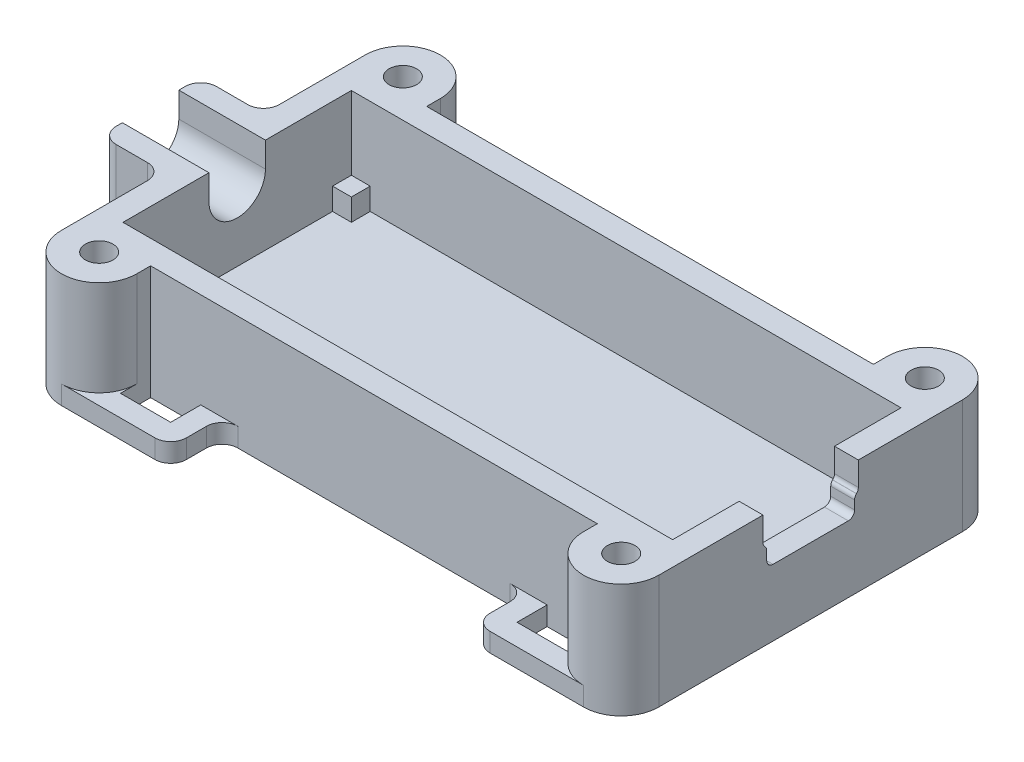
from build123d import *

# Parameters (mm, degrees)
SKETCH1_W           = 43.8
SKETCH1_H           = 18.2
SKETCH1_R           = 1.1
BOSS_EXTRUDE1_DEPTH = 7.6
SKETCH3_R           = 1.1
BOSS_EXTRUDE2_DEPTH = 1.5
CUT_EXTRUDE1_REACH  = 54.6
SKETCH5_W           = 1.5
SKETCH5_H           = 1.5
BOSS_EXTRUDE3_DEPTH = 1.75
CUT_EXTRUDE2_REACH  = 54.6
BOSS_EXTRUDE4_DEPTH = 1.5
FILLET1_R           = 1.25
FILLET2_R           = 0.5


with BuildPart() as part:
    # Sketch1 → Boss-Extrude1 (new body)
    with BuildSketch(Plane(origin=(0, 0, 0), x_dir=(1, 0, 0), z_dir=(0, 1, 0))):
        with BuildLine():
            ThreePointArc((-23.8, -12.1), (-20.8, -15.1), (-17.8, -12.1))
            Line((-17.8, -12.1), (-17.8, -11))
            Line((-17.8, -11), (17.8, -11))
            Line((17.8, -11), (17.8, -12.1))
            ThreePointArc((17.8, -12.1), (20.8, -15.1), (23.8, -12.1))
            Line((23.8, -12.1), (23.8, 12.1))
            ThreePointArc((23.8, 12.1), (20.8, 15.1), (17.8, 12.1))
            Line((17.8, 12.1), (17.8, 11))
            Line((17.8, 11), (-17.8, 11))
            Line((-17.8, 11), (-17.8, 12.1))
            ThreePointArc((-17.8, 12.1), (-20.8, 15.1), (-23.8, 12.1))
            Line((-23.8, 12.1), (-23.8, 4))
            Line((-23.8, 4), (-28.8, 4))
            Line((-28.8, 4), (-28.8, -4))
            Line((-28.8, -4), (-23.8, -4))
            Line((-23.8, -4), (-23.8, -12.1))
        make_face()
        Rectangle(SKETCH1_W, SKETCH1_H, mode=Mode.SUBTRACT)
        with Locations((-20.8, 12.1)):
            Circle(SKETCH1_R, mode=Mode.SUBTRACT)
        with Locations((20.8, 12.1)):
            Circle(SKETCH1_R, mode=Mode.SUBTRACT)
        with Locations((-20.8, -12.1)):
            Circle(SKETCH1_R, mode=Mode.SUBTRACT)
        with Locations((20.8, -12.1)):
            Circle(SKETCH1_R, mode=Mode.SUBTRACT)
    extrude(amount=BOSS_EXTRUDE1_DEPTH)

    # Sketch3 → Boss-Extrude2 (add)
    with BuildSketch(Plane.XZ):
        with BuildLine():
            Line((-23.8, -4), (-23.8, -12.1))
            ThreePointArc((-23.8, -12.1), (-20.8, -15.1), (-17.8, -12.1))
            Line((-17.8, -12.1), (-17.8, -11))
            Line((-17.8, -11), (17.8, -11))
            Line((17.8, -11), (17.8, -12.1))
            ThreePointArc((17.8, -12.1), (20.8, -15.1), (23.8, -12.1))
            Line((23.8, -12.1), (23.8, 12.1))
            ThreePointArc((23.8, 12.1), (20.8, 15.1), (17.8, 12.1))
            Line((17.8, 12.1), (17.8, 11))
            Line((17.8, 11), (-17.8, 11))
            Line((-17.8, 11), (-17.8, 12.1))
            ThreePointArc((-17.8, 12.1), (-20.8, 15.1), (-23.8, 12.1))
            Line((-23.8, 12.1), (-23.8, 4))
            Line((-23.8, 4), (-28.8, 4))
            Line((-28.8, 4), (-28.8, -4))
            Line((-28.8, -4), (-23.8, -4))
        make_face()
        with Locations((-20.8, -12.1)):
            Circle(SKETCH3_R, mode=Mode.SUBTRACT)
        with Locations((20.8, -12.1)):
            Circle(SKETCH3_R, mode=Mode.SUBTRACT)
        with Locations((20.8, 12.1)):
            Circle(SKETCH3_R, mode=Mode.SUBTRACT)
        with Locations((-20.8, 12.1)):
            Circle(SKETCH3_R, mode=Mode.SUBTRACT)
    extrude(amount=BOSS_EXTRUDE2_DEPTH)

    # Sketch4 → Cut-Extrude1 (cut, up to next)
    with BuildSketch(Plane.ZY.offset(28.8), mode=Mode.PRIVATE) as cut_extrude1_sk1:
        with BuildLine():
            Line((-2.25, 7.6), (-2.25, 5.6))
            ThreePointArc((-2.25, 5.6), (0, 3.35), (2.25, 5.6))
            Line((2.25, 5.6), (2.25, 7.6))
            Line((2.25, 7.6), (-2.25, 7.6))
        make_face()
    cut_extrude1_tool1 = extrude(cut_extrude1_sk1.sketch, amount=-CUT_EXTRUDE1_REACH, mode=Mode.PRIVATE) & part.part
    add(cut_extrude1_tool1.solids().sort_by_distance((-28.8, 5.682954, 0))[0], mode=Mode.SUBTRACT)

    # Sketch5 → Boss-Extrude3 (add)
    with BuildSketch(Plane(origin=(0, 0, 0), x_dir=(1, 0, 0), z_dir=(0, 1, 0))):
        with Locations((-21.15, 8.35)):
            Rectangle(SKETCH5_W, SKETCH5_H)
        with Locations((21.15, 8.35)):
            Rectangle(SKETCH5_W, SKETCH5_H)
        with Locations((-21.15, -8.35)):
            Rectangle(SKETCH5_W, SKETCH5_H)
        with Locations((21.15, -8.35)):
            Rectangle(SKETCH5_W, SKETCH5_H)
    extrude(amount=BOSS_EXTRUDE3_DEPTH)

    # Sketch6 → Cut-Extrude2 (cut, up to next)
    with BuildSketch(Plane(origin=(23.8, 0, 0), x_dir=(0, 0, -1), z_dir=(1, 0, 0)), mode=Mode.PRIVATE) as cut_extrude2_sk1:
        Polygon((3.8, 7.6), (-3.8, 7.6), (-3.8, 5.5), (-3.5, 5.2), (-3.5, 3.8), (3.5, 3.8), (3.5, 5.2), (3.8, 5.5), align=None)
    cut_extrude2_tool1 = extrude(cut_extrude2_sk1.sketch, amount=-CUT_EXTRUDE2_REACH, mode=Mode.PRIVATE) & part.part
    add(cut_extrude2_tool1.solids().sort_by_distance((23.8, 5.737352, 0))[0], mode=Mode.SUBTRACT)

    # Sketch8 → Boss-Extrude4 (add)
    with BuildSketch(Plane.XZ.offset(1.5)):
        with BuildLine():
            Line((-12.1, 15.1), (-20.8, 15.1))
            ThreePointArc((-20.8, 15.1), (-18.678679656, 14.221320344), (-17.8, 12.1))
            Line((-17.8, 12.1), (-17.8, 13.4))
            Line((-17.8, 13.4), (-13.8, 13.4))
            Line((-13.8, 13.4), (-13.8, 11))
            Line((-13.8, 11), (-12.1, 11))
            Line((-12.1, 11), (-12.1, 15.1))
        make_face()
        with BuildLine():
            Line((12.1, 15.1), (12.1, 11))
            Line((12.1, 11), (13.8, 11))
            Line((13.8, 11), (13.8, 13.4))
            Line((13.8, 13.4), (17.8, 13.4))
            Line((17.8, 13.4), (17.8, 12.1))
            ThreePointArc((17.8, 12.1), (18.678679656, 14.221320344), (20.8, 15.1))
            Line((20.8, 15.1), (12.1, 15.1))
        make_face()
        with BuildLine():
            Line((13.8, -11), (12.1, -11))
            Line((12.1, -11), (12.1, -15.1))
            Line((12.1, -15.1), (20.8, -15.1))
            ThreePointArc((20.8, -15.1), (18.678679656, -14.221320344), (17.8, -12.1))
            Line((17.8, -12.1), (17.8, -13.4))
            Line((17.8, -13.4), (13.8, -13.4))
            Line((13.8, -13.4), (13.8, -11))
        make_face()
        with BuildLine():
            Line((-20.8, -15.1), (-12.1, -15.1))
            Line((-12.1, -15.1), (-12.1, -11))
            Line((-12.1, -11), (-13.8, -11))
            Line((-13.8, -11), (-13.8, -13.4))
            Line((-13.8, -13.4), (-17.8, -13.4))
            Line((-17.8, -13.4), (-17.8, -12.1))
            ThreePointArc((-17.8, -12.1), (-18.678679656, -14.221320344), (-20.8, -15.1))
        make_face()
    extrude(amount=-BOSS_EXTRUDE4_DEPTH)

    # Fillet1
    fillet1_edges = [part.edges().sort_by_distance(p)[0] for p in [
        (-12.1, -0.75, 15.1),
        (-12.1, -0.75, 11),
        (12.1, -0.75, 11),
        (12.1, -0.75, 15.1),
        (12.1, -0.75, -15.1),
        (12.1, -0.75, -11),
        (-12.1, -0.75, -11),
        (-12.1, -0.75, -15.1),
        (-23.8, 3.05, 4),
        (-28.8, 3.05, 4),
        (-28.8, 3.05, -4),
        (-23.8, 3.05, -4),
    ]]
    fillet(fillet1_edges, radius=FILLET1_R)

    # Fillet2
    fillet2_edges = [part.edges().sort_by_distance(p)[0] for p in [
        (22.85, 5.2, -3.5),
        (22.85, 3.8, -3.5),
        (22.85, 3.8, 3.5),
        (22.85, 5.2, 3.5),
        (22.85, 5.5, 3.8),
        (22.85, 5.5, -3.8),
    ]]
    fillet(fillet2_edges, radius=FILLET2_R)


solid = part.part
